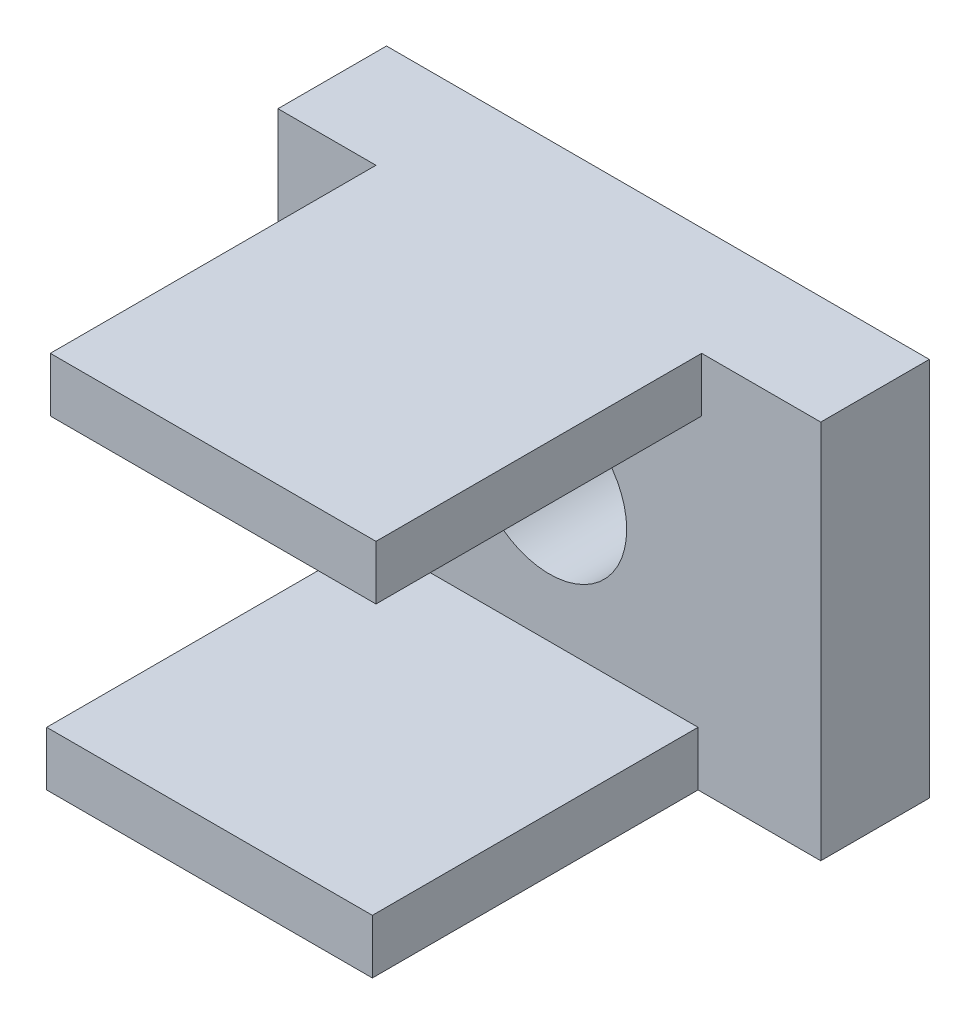
from build123d import *

# Parameters (mm, degrees)
SKETCH1_W           = 10
SKETCH1_H           = 7
BOSS_EXTRUDE1_DEPTH = 2
SKETCH2_W           = 6
SKETCH2_H           = 1
BOSS_EXTRUDE2_DEPTH = 6
SKETCH3_R           = 1.425
CUT_EXTRUDE1_DEPTH  = 6


with BuildPart() as part:
    # Sketch1 → Boss-Extrude1 (new body)
    with BuildSketch(Plane.XY):
        Rectangle(SKETCH1_W, SKETCH1_H)
    extrude(amount=BOSS_EXTRUDE1_DEPTH)

    # Sketch2 → Boss-Extrude2 (add)
    with BuildSketch(Plane.XY.offset(2)):
        with Locations((-0.193923398, 3)):
            Rectangle(SKETCH2_W, SKETCH2_H)
        with Locations((-0.260503556, -3)):
            Rectangle(SKETCH2_W, SKETCH2_H)
    extrude(amount=BOSS_EXTRUDE2_DEPTH)

    # Sketch3 → Cut-Extrude1 (cut)
    with BuildSketch(Plane.XY.offset(2)):
        Circle(SKETCH3_R)
    extrude(amount=-CUT_EXTRUDE1_DEPTH, mode=Mode.SUBTRACT)


solid = part.part
